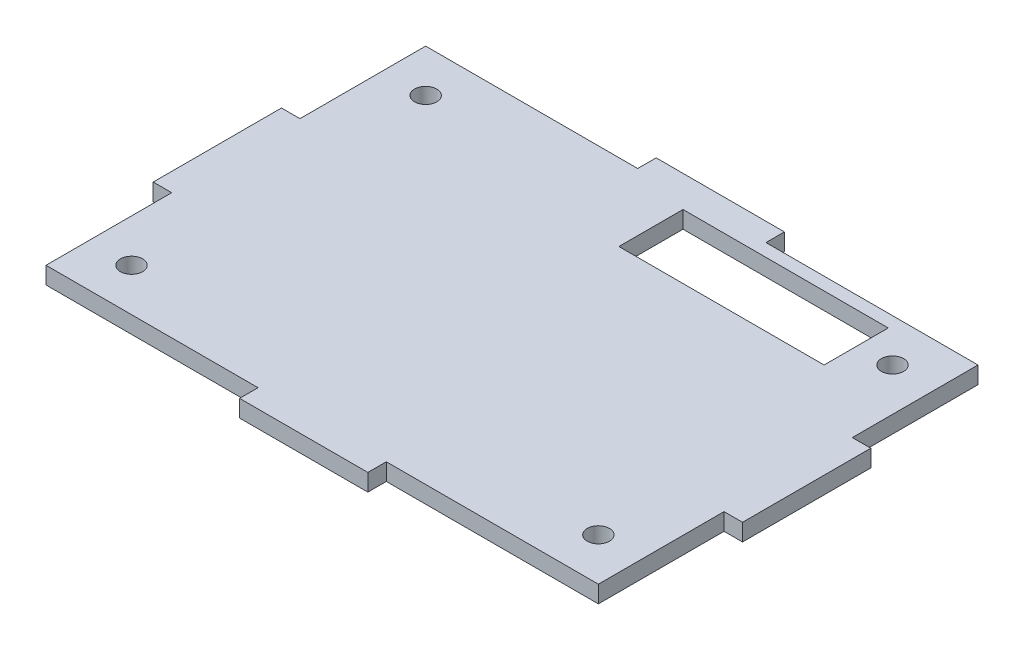
from build123d import *

# Parameters (mm, degrees)
SKETCH1_W           = 82.042
SKETCH1_H           = 56.388
SKETCH1_R           = 1.651
BOSS_EXTRUDE1_DEPTH = 2.54
SKETCH2_W           = 19.05
SKETCH2_H           = 2.7432
SKETCH2_W_2         = 2.7432
SKETCH2_H_2         = 19.05
BOSS_EXTRUDE2_DEPTH = 2.54
SKETCH3_W           = 30.48
SKETCH3_H           = 9.525
CUT_EXTRUDE1_DEPTH  = 3.54


with BuildPart() as part:
    # Sketch1 → Boss-Extrude1 (new body)
    with BuildSketch(Plane(origin=(0, 0, 0), x_dir=(1, 0, 0), z_dir=(0, 1, 0))):
        Rectangle(SKETCH1_W, SKETCH1_H)
        with Locations((-34.671, 21.844)):
            Circle(SKETCH1_R, mode=Mode.SUBTRACT)
        with Locations((-34.671, -21.844)):
            Circle(SKETCH1_R, mode=Mode.SUBTRACT)
        with Locations((34.671, -21.844)):
            Circle(SKETCH1_R, mode=Mode.SUBTRACT)
        with Locations((34.671, 21.844)):
            Circle(SKETCH1_R, mode=Mode.SUBTRACT)
    extrude(amount=BOSS_EXTRUDE1_DEPTH)

    # Sketch2 → Boss-Extrude2 (add)
    with BuildSketch(Plane(origin=(0, 2.54, 0), x_dir=(1, 0, 0), z_dir=(0, 1, 0))):
        with Locations((0, 29.5656)):
            Rectangle(SKETCH2_W, SKETCH2_H)
        with Locations((0, -29.5656)):
            Rectangle(SKETCH2_W, SKETCH2_H)
        with Locations((42.3926, 0)):
            Rectangle(SKETCH2_W_2, SKETCH2_H_2)
        with Locations((-42.3926, 0)):
            Rectangle(SKETCH2_W_2, SKETCH2_H_2)
    extrude(amount=-BOSS_EXTRUDE2_DEPTH)

    # Sketch3 → Cut-Extrude1 (cut, through all)
    with BuildSketch(Plane(origin=(0, 2.54, 0), x_dir=(1, 0, 0), z_dir=(0, 1, 0))):
        with Locations((14.351, 21.5265)):
            Rectangle(SKETCH3_W, SKETCH3_H)
    extrude(amount=-CUT_EXTRUDE1_DEPTH, mode=Mode.SUBTRACT)


solid = part.part
